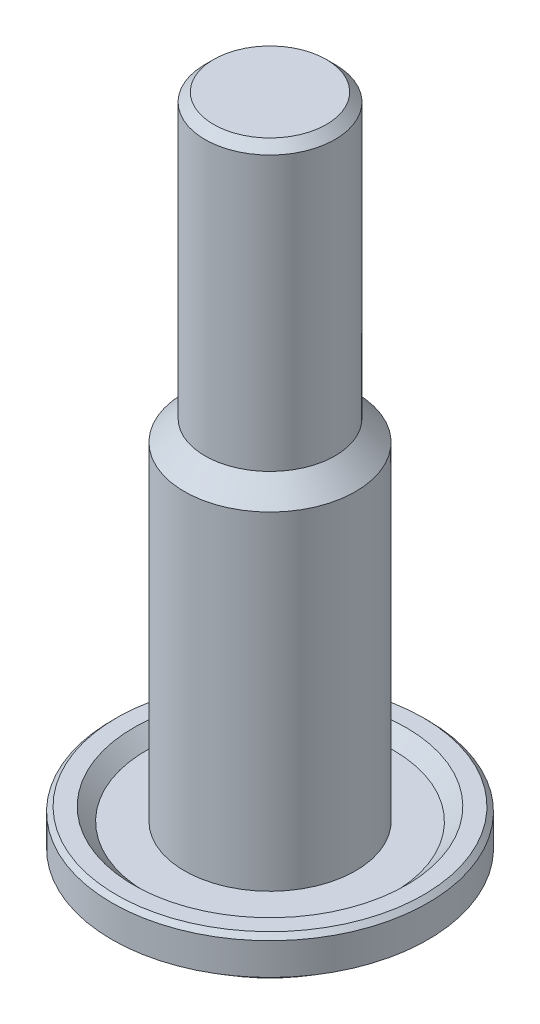
from build123d import *


with BuildPart() as part:
    # Sketch2 → Revolve1 (revolve)
    with BuildSketch(Plane(origin=(0, 0, 0), x_dir=(0, 0, -1), z_dir=(1, 0, 0))):
        Polygon((0, 40.0558), (-3.302, 40.0558), (-3.81, 39.5478), (-3.81, 23.495), (-5.0165, 22.2885), (-5.0165, 3.048), (-7.2263, 3.048), (-7.9883, 3.81), (-8.988892316, 3.81), (-9.2583, 3.540592316), (-9.2583, 1.6764), (-6.9342, 0), (-2.54, 0), (-2.54, 20.955), (0, 20.955), align=None)
    revolve(axis=Axis((0, 20.955, 0), (0, 1, 0)))


solid = part.part
